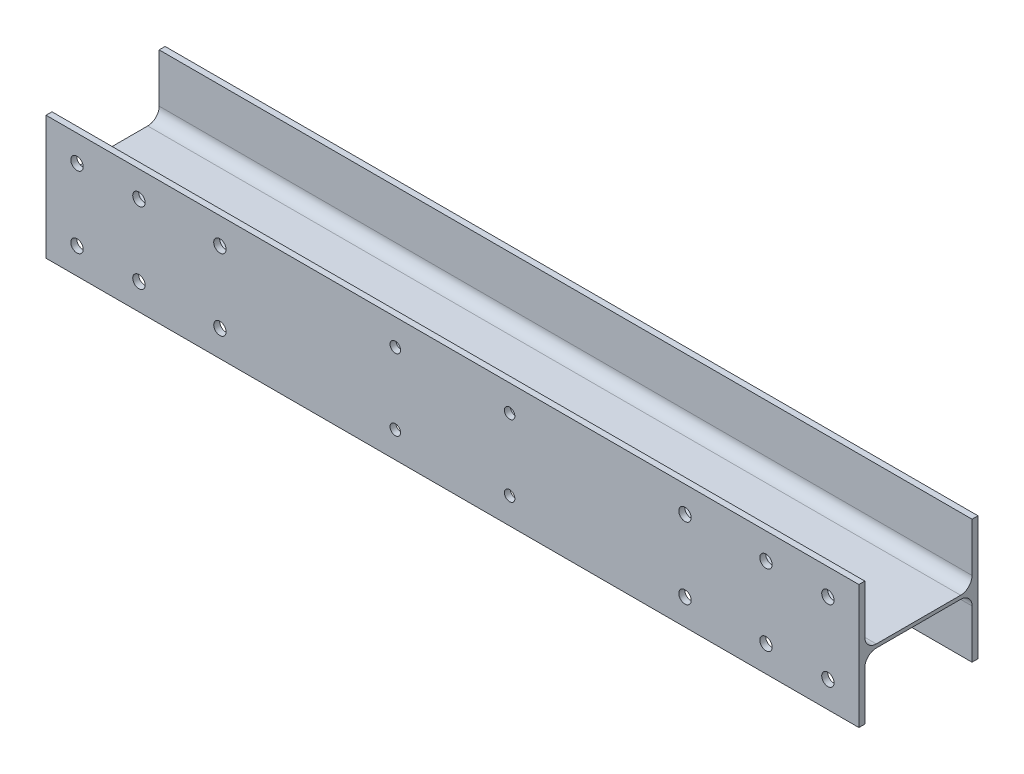
from build123d import *

# Parameters (mm, degrees)
STRUKTURBAUTEIL1_DEPTH          = 1706
SKIZZE2_R                       = 13
SKIZZE2_R_2                     = 11
SCHNITT_LINEAR_AUSTRAGEN1_DEPTH = 12.5


with BuildPart() as part:
    # Skizze12 → Strukturbauteil1 (new body)
    with BuildSketch(Plane(origin=(853, 0, 0), x_dir=(0, -1, 0), z_dir=(-1, 0, 0))):
        with BuildLine():
            Line((130, 125), (-130, 125))
            Line((-130, 125), (-130, 112.5))
            Line((-130, 112.5), (-27.75, 112.5))
            ThreePointArc((-27.75, 112.5), (-10.779437252, 105.470562748), (-3.75, 88.5))
            Line((-3.75, 88.5), (-3.75, -88.5))
            ThreePointArc((-3.75, -88.5), (-10.779437252, -105.470562748), (-27.75, -112.5))
            Line((-27.75, -112.5), (-130, -112.5))
            Line((-130, -112.5), (-130, -125))
            Line((-130, -125), (130, -125))
            Line((130, -125), (130, -112.5))
            Line((130, -112.5), (27.75, -112.5))
            ThreePointArc((27.75, -112.5), (10.779437252, -105.470562748), (3.75, -88.5))
            Line((3.75, -88.5), (3.75, 88.5))
            ThreePointArc((3.75, 88.5), (10.779437252, 105.470562748), (27.75, 112.5))
            Line((27.75, 112.5), (130, 112.5))
            Line((130, 112.5), (130, 125))
        make_face()
    extrude(amount=STRUKTURBAUTEIL1_DEPTH)

    # Skizze2 → Schnitt-Linear austragen1 (cut)
    with BuildSketch(Plane.XY.offset(125)):
        with Locations((-788, 75)):
            Circle(SKIZZE2_R)
        with Locations((-788, -75)):
            Circle(SKIZZE2_R)
        with Locations((-658, -75)):
            Circle(SKIZZE2_R)
        with Locations((-658, 75)):
            Circle(SKIZZE2_R)
        with Locations((-488, 75)):
            Circle(SKIZZE2_R)
        with Locations((-488, -75)):
            Circle(SKIZZE2_R)
        with Locations(Location((488, -75, 0), (0, 0, 270))):  # turned: the seam where the file's is
            Circle(SKIZZE2_R)
        with Locations(Location((488, 75, 0), (0, 0, 270))):  # turned: the seam where the file's is
            Circle(SKIZZE2_R)
        with Locations(Location((658, 75, 0), (0, 0, 270))):  # turned: the seam where the file's is
            Circle(SKIZZE2_R)
        with Locations(Location((658, -75, 0), (0, 0, 270))):  # turned: the seam where the file's is
            Circle(SKIZZE2_R)
        with Locations(Location((788, -75, 0), (0, 0, 270))):  # turned: the seam where the file's is
            Circle(SKIZZE2_R)
        with Locations(Location((788, 75, 0), (0, 0, 270))):  # turned: the seam where the file's is
            Circle(SKIZZE2_R)
        with Locations((-120, 75)):
            Circle(SKIZZE2_R_2)
        with Locations((120, 75)):
            Circle(SKIZZE2_R_2)
        with Locations((-120, -75)):
            Circle(SKIZZE2_R_2)
        with Locations((120, -75)):
            Circle(SKIZZE2_R_2)
    extrude(amount=-SCHNITT_LINEAR_AUSTRAGEN1_DEPTH, mode=Mode.SUBTRACT)


solid = part.part
